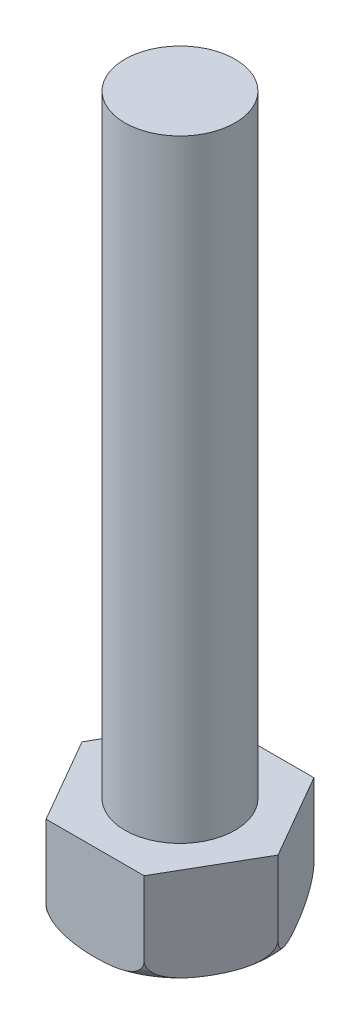
from build123d import *

# Parameters (mm, degrees)
BOSS_EXTRUDE1_DEPTH = 2
SKETCH2_R           = 2.25
BOSS_EXTRUDE2_DEPTH = 25


with BuildPart() as part:
    # Sketch1 → Boss-Extrude1 (new body, symmetric)
    with BuildSketch(Plane(origin=(0, 0, 0), x_dir=(1, 0, 0), z_dir=(0, 1, 0))):
        Polygon((4, 0), (2, 3.464101615), (-2, 3.464101615), (-4, 0), (-2, -3.464101615), (2, -3.464101615), align=None)
    extrude(amount=BOSS_EXTRUDE1_DEPTH, both=True)

    # Sketch2 → Boss-Extrude2 (add)
    with BuildSketch(Plane(origin=(0, 2, 0), x_dir=(1, 0, 0), z_dir=(0, 1, 0))):
        Circle(SKETCH2_R)
    extrude(amount=BOSS_EXTRUDE2_DEPTH)

    # Sketch3 → Cut-Revolve1 (revolve, cut)
    with BuildSketch(Plane.XY):
        with BuildLine():
            Line((2.248897347, -2), (3, -2))
            ThreePointArc((3, -2), (3.707106781, -1.707106781), (4, -1))
            Line((4, -1), (4, -0.81272303))
            Line((4, -0.81272303), (5.594351863, -2.268615273))
            Line((5.594351863, -2.268615273), (3.350773239, -3.273136669))
            Line((3.350773239, -3.273136669), (2.248897347, -2))
        make_face()
    revolve(axis=Axis((0, -2, 0), (0, -1, 0)), mode=Mode.SUBTRACT)


solid = part.part
